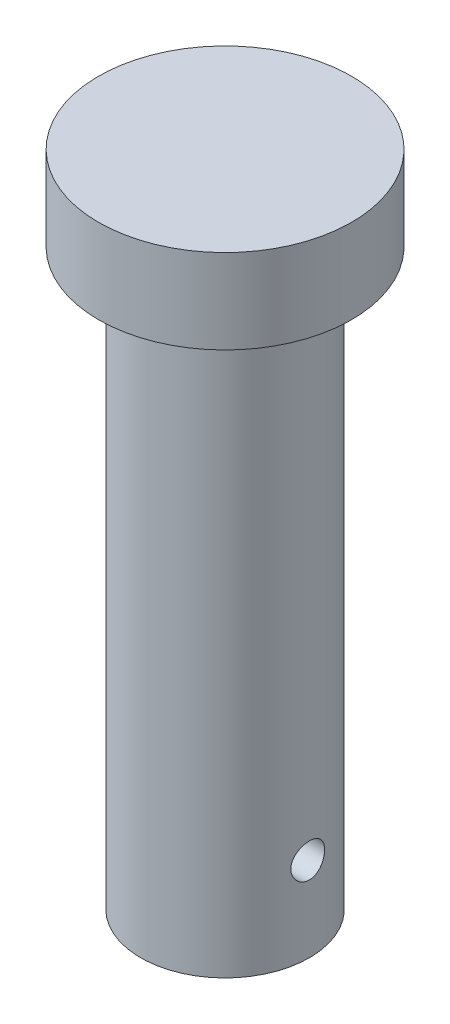
from build123d import *

# Parameters (mm, degrees)
SKETCH1_R               = 22.5
BOSS_EXTRUDE1_DEPTH     = 15
SKETCH2_R               = 15
BOSS_EXTRUDE2_DEPTH     = 102
CUT_EXTRUDE1_DEPTH      = 122.249742268
CUT_EXTRUDE1_DEPTH_BACK = 31
SKETCH3_R               = 3


with BuildPart() as part:
    # Sketch1 → Boss-Extrude1 (new body)
    with BuildSketch(Plane(origin=(0, 0, 0), x_dir=(1, 0, 0), z_dir=(0, 1, 0))):
        Circle(SKETCH1_R)
    extrude(amount=-BOSS_EXTRUDE1_DEPTH)

    # Sketch2 → Boss-Extrude2 (add)
    with BuildSketch(Plane.XZ.offset(15)):
        Circle(SKETCH2_R)
    extrude(amount=BOSS_EXTRUDE2_DEPTH)

    # Sketch3 → Cut-Extrude1 (cut, two sides: drawn at the far end of the back side and taken through both)
    with BuildSketch(Plane(origin=(0, 0, 0), x_dir=(0, 0, -1), z_dir=(1, 0, 0)).offset(-CUT_EXTRUDE1_DEPTH_BACK)):
        with Locations((0, -102)):
            Circle(SKETCH3_R)
    extrude(amount=CUT_EXTRUDE1_DEPTH + CUT_EXTRUDE1_DEPTH_BACK, mode=Mode.SUBTRACT)


solid = part.part
